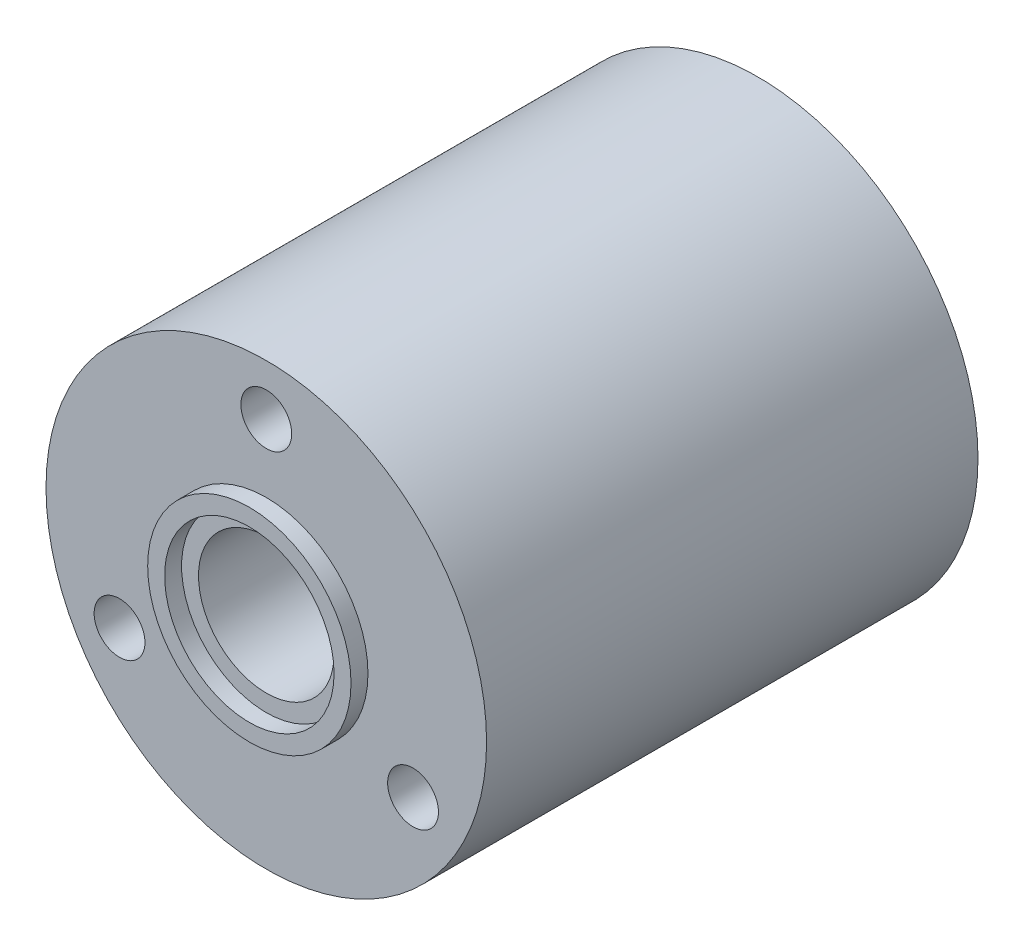
from build123d import *

# Parameters (mm, degrees)
SKETCH1_R           = 13
SKETCH1_R_2         = 5
BOSS_EXTRUDE1_DEPTH = 29
SKETCH2_R           = 6
SKETCH2_R_2         = 5
BOSS_EXTRUDE2_DEPTH = 1
SKETCH3_R           = 1.5
CUT_EXTRUDE1_DEPTH  = 31
SKETCH4_R           = 5
SKETCH4_R_2         = 4
BOSS_EXTRUDE3_DEPTH = 29


with BuildPart() as part:
    # Sketch1 → Boss-Extrude1 (new body)
    with BuildSketch(Plane.XY):
        Circle(SKETCH1_R)
        Circle(SKETCH1_R_2, mode=Mode.SUBTRACT)
    extrude(amount=BOSS_EXTRUDE1_DEPTH)

    # Sketch2 → Boss-Extrude2 (add)
    with BuildSketch(Plane.XY.offset(29)):
        Circle(SKETCH2_R)
        Circle(SKETCH2_R_2, mode=Mode.SUBTRACT)
    boss_extrude2 = extrude(amount=BOSS_EXTRUDE2_DEPTH)

    # Mirror1: Boss-Extrude2 across plane
    add(boss_extrude2.mirror(Plane.XY.offset(14.5)))

    # Sketch3 → Cut-Extrude1 (cut, through all)
    with BuildSketch(Plane.XY.offset(29)):
        with Locations((0, 10)):
            Circle(SKETCH3_R)
        with Locations((8.660254038, -5)):
            Circle(SKETCH3_R)
        with Locations((-8.660254038, -5)):
            Circle(SKETCH3_R)
    extrude(amount=-CUT_EXTRUDE1_DEPTH, mode=Mode.SUBTRACT)

    # Sketch4 → Boss-Extrude3 (add)
    with BuildSketch(Plane.XY.offset(29)):
        Circle(SKETCH4_R)
        Circle(SKETCH4_R_2, mode=Mode.SUBTRACT)
    extrude(amount=-BOSS_EXTRUDE3_DEPTH)


solid = part.part
